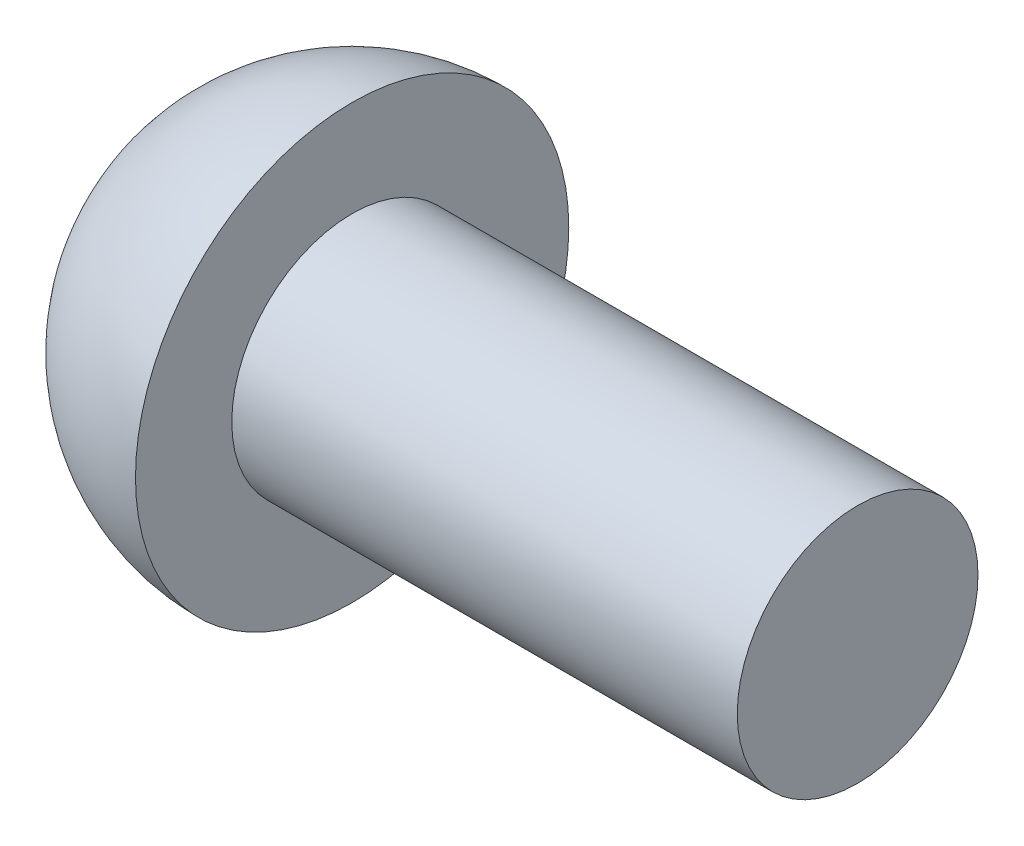
from build123d import *


with BuildPart() as part:
    # 草圖1 → 旋轉1 (revolve)
    with BuildSketch(Plane(origin=(0, 0, 0), x_dir=(1, 0, 0), z_dir=(0, 1, 0))):
        with BuildLine():
            Line((0, 0), (21, 0))
            Line((21, 0), (21, 5))
            Line((21, 5), (0, 5))
            Line((0, 5), (0, 9))
            ThreePointArc((0, 9), (-6.363961031, 6.363961031), (-9, 0))
            Line((-9, 0), (0, 0))
        make_face()
    revolve(axis=Axis((0, 0, 0), (1, 0, 0)))


solid = part.part
